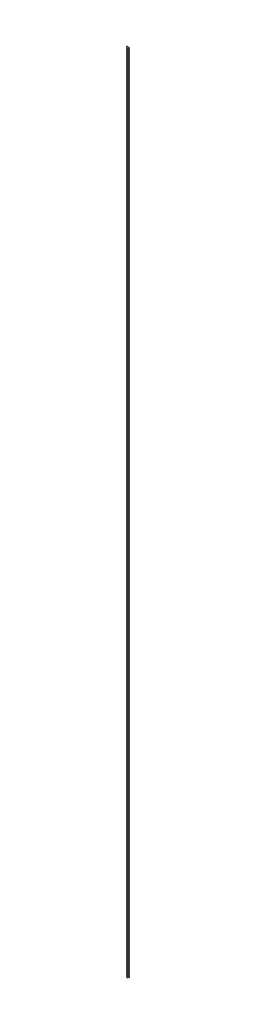
from build123d import *

# Parameters (mm, degrees)
BOSS_EXTRUDE1_DEPTH = 18288


with BuildPart() as part:
    # Sketch1 → Boss-Extrude1 (new body)
    with BuildSketch(Plane(origin=(0, 0, 0), x_dir=(1, 0, 0), z_dir=(0, 1, 0))):
        Polygon((-31.75, -6.35), (31.75, -6.35), (31.75, -12.7), (12.7, -12.7), (12.7, -38.1), (-12.7, -38.1), (-12.7, -12.7), (-31.75, -12.7), align=None)
    extrude(amount=BOSS_EXTRUDE1_DEPTH)


solid = part.part
